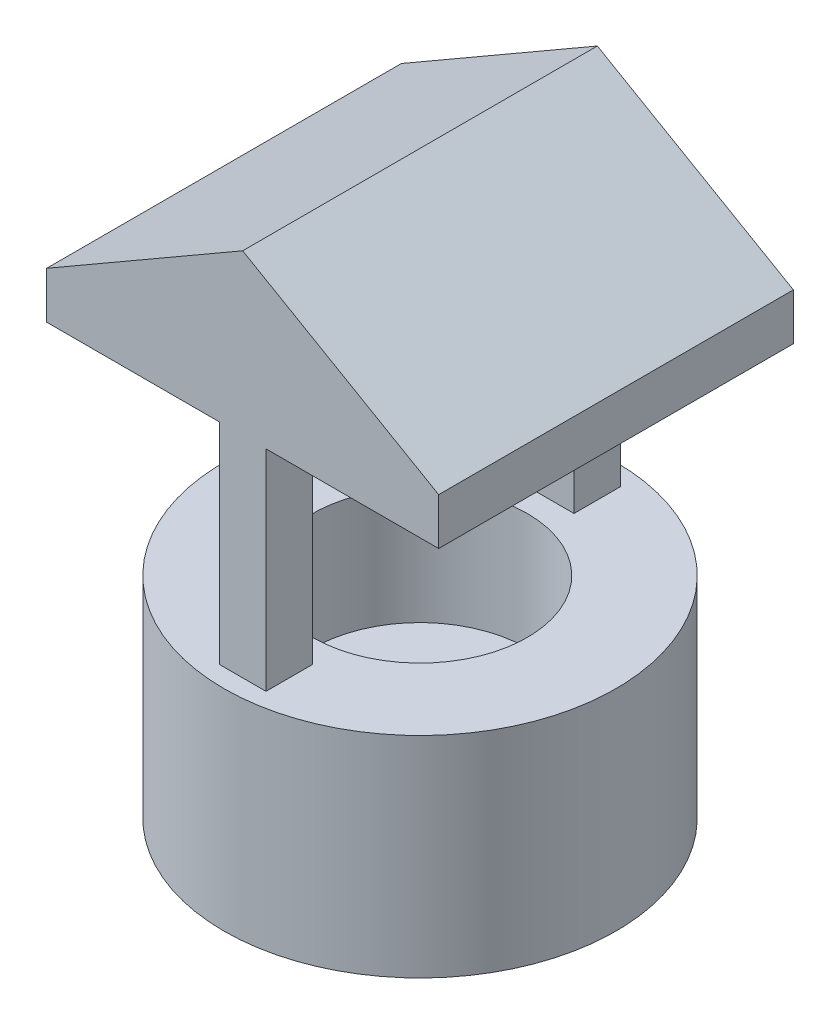
from build123d import *

# Parameters (mm, degrees)
SKETCH1_R                = 42
BOSS_EXTRUDE1_DEPTH      = 45
SKETCH2_R                = 23
CUT_EXTRUDE1_DEPTH       = 25
BOSS_EXTRUDE2_DEPTH      = 38
BOSS_EXTRUDE2_DEPTH_BACK = 38
SKETCH4_W                = 10
SKETCH4_H                = 10
BOSS_EXTRUDE4_DEPTH      = 45


with BuildPart() as part:
    # Sketch1 → Boss-Extrude1 (new body)
    with BuildSketch(Plane(origin=(0, 0, 0), x_dir=(1, 0, 0), z_dir=(0, 1, 0))):
        with Locations(Location((0, 0, 0), (0, 0, 270))):  # turned: the seam where the file's is
            Circle(SKETCH1_R)
    extrude(amount=BOSS_EXTRUDE1_DEPTH)

    # Sketch2 → Cut-Extrude1 (cut)
    with BuildSketch(Plane(origin=(0, 45, 0), x_dir=(1, 0, 0), z_dir=(0, 1, 0))):
        with Locations(Location((0, 0, 0), (0, 0, 270))):  # turned: the seam where the file's is
            Circle(SKETCH2_R)
    extrude(amount=-CUT_EXTRUDE1_DEPTH, mode=Mode.SUBTRACT)



with BuildPart() as body_2:
    # Sketch3 → Boss-Extrude2 (new body, two sides)
    with BuildSketch(Plane.XY) as boss_extrude2_sk:
        Polygon((-42, 100), (-42, 90), (42, 90), (42, 100), (0, 124.248711306), align=None)
    extrude(amount=BOSS_EXTRUDE2_DEPTH)
    extrude(boss_extrude2_sk.sketch, amount=-BOSS_EXTRUDE2_DEPTH_BACK)


with BuildPart() as part_1:
    add(part.part)

    add(body_2.part)  # Boss-Extrude4 merges body 2
    # Sketch4 → Boss-Extrude4 (add)
    with BuildSketch(Plane.XZ.offset(-90)):
        with Locations((0, 33)):
            Rectangle(SKETCH4_W, SKETCH4_H)
    boss_extrude4 = extrude(amount=BOSS_EXTRUDE4_DEPTH)

    # Mirror1: Boss-Extrude4 across plane
    add(boss_extrude4.mirror(Plane.XY))


solid = part_1.part
